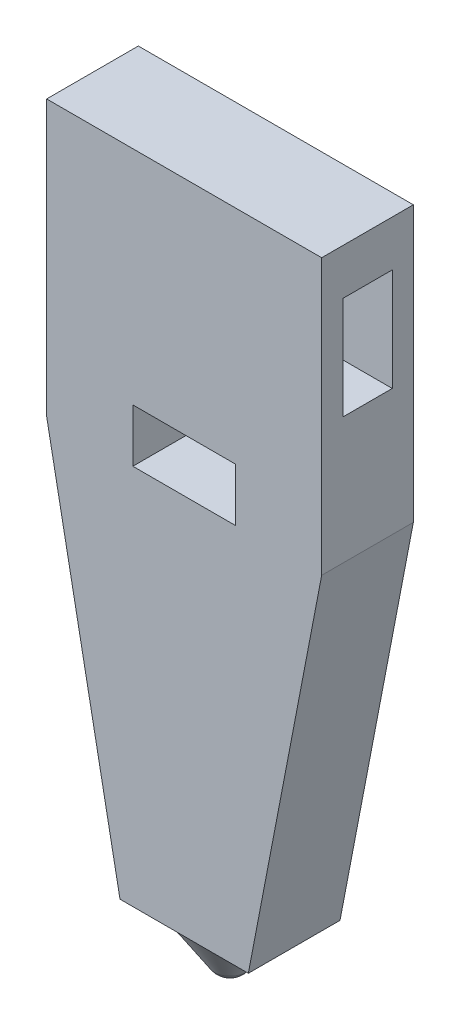
from build123d import *

# Parameters (mm, degrees)
BOSS_EXTRUDE1_DEPTH = 6.35
SKETCH3_W           = 3.429
SKETCH3_H           = 7.112
CUT_EXTRUDE1_DEPTH  = 20.05
SKETCH4_W           = 7.112
SKETCH4_H           = 3.683
CUT_EXTRUDE2_DEPTH  = 7.35


with BuildPart() as part:
    # Sketch1 → Boss-Extrude1 (new body)
    with BuildSketch(Plane.XY):
        Polygon((0, -19.05), (5.08, -45.466), (13.97, -45.466), (19.05, -19.05), (19.05, 0), (0, 0), align=None)
    extrude(amount=BOSS_EXTRUDE1_DEPTH)

    # Sketch2 → Revolve1 (revolve)
    with BuildSketch(Plane.XY.offset(3.175)):
        with BuildLine():
            Line((9.525, -45.466), (12.7, -45.466))
            Line((12.7, -45.466), (10.588425211, -48.700281514))
            ThreePointArc((10.588425211, -48.700281514), (10.129633144, -49.122834259), (9.525, -49.276))
            Line((9.525, -49.276), (9.525, -45.466))
        make_face()
    revolve(axis=Axis((9.525, -49.276, 3.175), (0, 1, 0)))

    # Sketch3 → Cut-Extrude1 (cut, through all)
    with BuildSketch(Plane.ZY):
        with Locations((3.175, -6.731)):
            Rectangle(SKETCH3_W, SKETCH3_H)
    extrude(amount=-CUT_EXTRUDE1_DEPTH, mode=Mode.SUBTRACT)

    # Sketch4 → Cut-Extrude2 (cut, through all)
    with BuildSketch(Plane.XY.offset(6.35)):
        with Locations((9.525, -17.2085)):
            Rectangle(SKETCH4_W, SKETCH4_H)
    extrude(amount=-CUT_EXTRUDE2_DEPTH, mode=Mode.SUBTRACT)


solid = part.part
